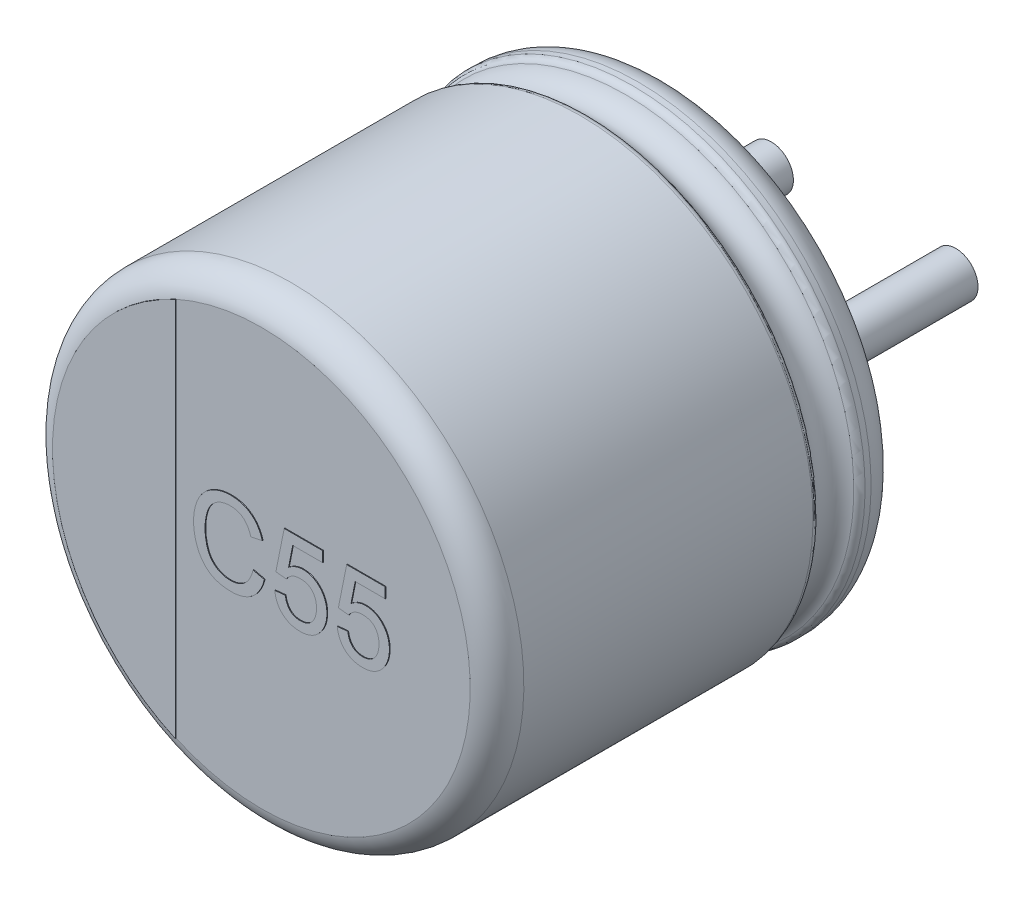
from build123d import *

# Parameters (mm, degrees)
SKETCH_2_R         = 0.3
EXTRUDE_1_DEPTH    = 2.7
EXTRUDE_2_DEPTH    = 0.01
EXTRUDE_1894_DEPTH = 0.01
EXTRUDE_5_DEPTH    = 0.05


with BuildPart() as part:
    # Sketch10 → Повернуть1 (revolve)
    with BuildSketch(Plane(origin=(0, 0, 0), x_dir=(0, 0, -1), z_dir=(1, 0, 0))):
        with BuildLine():
            Line((-5.5, 0), (-0.05, 0))
            Line((-0.05, 0), (-0.05, 2.553143426))
            ThreePointArc((-0.05, 2.553143426), (-0.052704561, 2.951565585), (-0.398206102, 3.15))
            Line((-0.398206102, 3.15), (-0.479422929, 3.15))
            ThreePointArc((-0.479422929, 3.15), (-0.534479696, 3.133479053), (-0.571344666, 3.089375046))
            ThreePointArc((-0.571344666, 3.089375046), (-0.831990181, 2.917472047), (-1.092635697, 3.089375046))
            ThreePointArc((-1.092635697, 3.089375046), (-1.129500666, 3.133479053), (-1.184557434, 3.15))
            Line((-1.184557434, 3.15), (-5.1, 3.15))
            ThreePointArc((-5.1, 3.15), (-5.35971595, 3.059961924), (-5.5, 2.82357323))
            Line((-5.5, 2.82357323), (-5.5, 0))
        make_face()
    revolve(axis=Axis((0, 0, -18.1630778), (0, 0, 1)))

    # Эскиз2 → Бобышка-Вытянуть1 (add)
    with BuildSketch(Plane(origin=(0, 0, 0.05), x_dir=(-1, 0, 0), z_dir=(0, 0, -1))):
        with Locations((-1.25, 0)):
            Circle(SKETCH_2_R)
        with Locations((1.25, 0)):
            Circle(SKETCH_2_R)
    extrude(amount=EXTRUDE_1_DEPTH)

    # Эскиз4 → Бобышка-Вытянуть2 (add)
    with BuildSketch(Plane.XY.offset(5.5)):
        with BuildLine():
            Line((-1.160332513, -2.574139515), (-1.160332513, 2.574139515))
            ThreePointArc((-1.160332513, 2.574139515), (-2.82357323, 0), (-1.160332513, -2.574139515))
        make_face()
    extrude(amount=EXTRUDE_2_DEPTH)

    # Эскиз5 → Extrude 1894 (add)
    with BuildSketch(Plane.XY.offset(5.5)):
        with BuildLine():
            Line((-0.108912855, -0.069918347), (0.04621535, -0.106056167))
            add(Edge.make_bspline(
                [(0.04621535, -0.106056167), (0.042328955, -0.120595903), (0.034726685, -0.149037431), (0.019696074, -0.189740405), (0.002826055, -0.22793841), (-0.016292712, -0.263530826), (-0.037869483, -0.296313018), (-0.061332559, -0.326706301), (-0.08761128, -0.354073299), (-0.115741448, -0.379045627), (-0.145942088, -0.401071154), (-0.177849082, -0.420090601), (-0.2113082, -0.436272289), (-0.246454673, -0.449579116), (-0.283311287, -0.459593644), (-0.321688266, -0.466892819), (-0.361697515, -0.471388685), (-0.388969191, -0.471980579), (-0.402863176, -0.472282129)],
                knots=[0, 0, 0, 0, 4.5129e-05, 8.8278e-05, 0.000130005, 0.00017033, 0.000209322, 0.000247627, 0.000285345, 0.000322969, 0.000360344, 0.000397303, 0.00043426, 0.000471708, 0.000509877, 0.000548685, 0.000588812, 0.000630487, 0.000630487, 0.000630487, 0.000630487], degree=3))
            add(Edge.make_bspline(
                [(-0.402863176, -0.472282129), (-0.417118674, -0.472075022), (-0.445008416, -0.471669834), (-0.48586528, -0.468374144), (-0.524724169, -0.462658281), (-0.561512517, -0.454716909), (-0.596354147, -0.444897895), (-0.629104581, -0.432544706), (-0.659706455, -0.417746474), (-0.68841503, -0.40091706), (-0.715108371, -0.381798088), (-0.740393493, -0.360905526), (-0.763656558, -0.337664227), (-0.785479231, -0.312622937), (-0.805386205, -0.285451329), (-0.824109863, -0.25651854), (-0.840736314, -0.225314775), (-0.855881721, -0.192418552), (-0.869175168, -0.158148367), (-0.880935219, -0.12318115), (-0.890549703, -0.087447226), (-0.898827154, -0.051247288), (-0.904840321, -0.01427674), (-0.90961459, 0.023187027), (-0.912239578, 0.061373697), (-0.912584999, 0.087042498), (-0.912759009, 0.09997348)],
                knots=[0, 0, 0, 0, 4.2763e-05, 8.3662e-05, 0.000122865, 0.000160509, 0.000196497, 0.000231366, 0.000265367, 0.000298359, 0.00033107, 0.000363769, 0.000396646, 0.000429606, 0.00046332, 0.000497611, 0.000532907, 0.000569289, 0.000606199, 0.00064313, 0.000679908, 0.000717169, 0.000754481, 0.000792226, 0.000830438, 0.00086923, 0.00086923, 0.00086923, 0.00086923], degree=3))
            add(Edge.make_bspline(
                [(-0.912759009, 0.09997348), (-0.912510138, 0.113932996), (-0.912018432, 0.141513475), (-0.909242757, 0.182209272), (-0.904144849, 0.221485694), (-0.897065337, 0.259368577), (-0.888106922, 0.295888601), (-0.877048763, 0.331063557), (-0.864030746, 0.364848441), (-0.849092557, 0.397280506), (-0.83213495, 0.427997725), (-0.81366404, 0.457043765), (-0.793239225, 0.483941703), (-0.771466071, 0.509205432), (-0.747800778, 0.532414283), (-0.72231561, 0.553620827), (-0.695230442, 0.573018497), (-0.666549228, 0.590427213), (-0.636646863, 0.605702449), (-0.605967495, 0.619308236), (-0.574389099, 0.630460027), (-0.542162036, 0.639732294), (-0.509216926, 0.647113879), (-0.475476789, 0.652049968), (-0.4409728, 0.655266706), (-0.417707516, 0.655702651), (-0.405948112, 0.655922999)],
                knots=[0, 0, 0, 0, 4.1881e-05, 8.2747e-05, 0.000122296, 0.00016063, 0.000198308, 0.000235036, 0.00027117, 0.000306859, 0.000342067, 0.000376357, 0.000410027, 0.000443298, 0.000476332, 0.000509341, 0.000542667, 0.000576187, 0.000609892, 0.00064334, 0.000676795, 0.000710271, 0.000743899, 0.000777992, 0.000812505, 0.000847779, 0.000847779, 0.000847779, 0.000847779], degree=3))
            add(Edge.make_bspline(
                [(-0.405948112, 0.655922999), (-0.392790923, 0.655674993), (-0.366929166, 0.655187511), (-0.328981645, 0.651177881), (-0.292637827, 0.64446219), (-0.25774023, 0.635651838), (-0.224651675, 0.623588633), (-0.19301293, 0.609246868), (-0.163138738, 0.592016975), (-0.134796652, 0.572372462), (-0.108448038, 0.5502771), (-0.083724175, 0.526258741), (-0.061633171, 0.499717103), (-0.04130009, 0.471294538), (-0.023364678, 0.440596924), (-0.007167108, 0.407891911), (0.006762331, 0.372936375), (0.014215274, 0.348588877), (0.018010222, 0.336191429)],
                knots=[0, 0, 0, 0, 3.9465e-05, 7.7573e-05, 0.00011431, 0.000150279, 0.000185409, 0.000219821, 0.000254368, 0.000288721, 0.000323141, 0.000357421, 0.000391983, 0.00042659, 0.000462151, 0.000498515, 0.000535996, 0.000574881, 0.000574881, 0.000574881, 0.000574881], degree=3))
            Line((0.018010222, 0.336191429), (-0.137117984, 0.302918192))
            add(Edge.make_bspline(
                [(-0.137117984, 0.302918192), (-0.140164459, 0.312432596), (-0.146127355, 0.331055231), (-0.15671506, 0.357595794), (-0.168149428, 0.382234108), (-0.180702836, 0.404802692), (-0.194402488, 0.425306953), (-0.20893292, 0.443996089), (-0.224642265, 0.460521265), (-0.241210981, 0.47526351), (-0.259066923, 0.487822492), (-0.277791469, 0.498951816), (-0.297779426, 0.508159635), (-0.318743252, 0.515947548), (-0.340878894, 0.521874989), (-0.364096214, 0.526045177), (-0.388415609, 0.528458678), (-0.404987911, 0.528817113), (-0.413440099, 0.528999922)],
                knots=[0, 0, 0, 0, 2.9963e-05, 5.8647e-05, 8.5657e-05, 0.000111404, 0.000136034, 0.000159573, 0.00018233, 0.000204345, 0.00022599, 0.00024772, 0.000269605, 0.000291914, 0.000314738, 0.000338251, 0.000362611, 0.000387967, 0.000387967, 0.000387967, 0.000387967], degree=3))
            add(Edge.make_bspline(
                [(-0.413440099, 0.528999922), (-0.423143984, 0.528859129), (-0.442228662, 0.528582229), (-0.47026635, 0.525551592), (-0.497192283, 0.52108776), (-0.522805782, 0.51439386), (-0.547247006, 0.506048307), (-0.570370917, 0.495656617), (-0.592374217, 0.483476338), (-0.613011338, 0.469434324), (-0.632108844, 0.453648399), (-0.650184985, 0.436960206), (-0.666371907, 0.418591447), (-0.681286864, 0.399147811), (-0.694495535, 0.378285716), (-0.706385552, 0.356289328), (-0.716881124, 0.332978371), (-0.72832201, 0.300169965), (-0.739987527, 0.257913496), (-0.750107378, 0.206205274), (-0.756553484, 0.153682392), (-0.757270938, 0.118354545), (-0.757630804, 0.100634538)],
                knots=[0, 0, 0, 0, 2.91e-05, 5.7231e-05, 8.4509e-05, 0.000110911, 0.000136555, 0.000161905, 0.00018686, 0.000211918, 0.000236663, 0.000261138, 0.00028564, 0.000310012, 0.000334585, 0.000359628, 0.000384977, 0.000411183, 0.00046379, 0.000516339, 0.000569145, 0.000622287, 0.000622287, 0.000622287, 0.000622287], degree=3))
            add(Edge.make_bspline(
                [(-0.757630804, 0.100634538), (-0.757224926, 0.078354594), (-0.756437487, 0.035129485), (-0.748667393, -0.027510838), (-0.73682082, -0.085937398), (-0.722523713, -0.131521756), (-0.708182278, -0.165145637), (-0.696583647, -0.188692925), (-0.683344271, -0.210482444), (-0.668793463, -0.230637938), (-0.652743794, -0.249100614), (-0.635418867, -0.265968548), (-0.616814812, -0.281404048), (-0.59671119, -0.29468455), (-0.575881813, -0.306476479), (-0.554589531, -0.316962087), (-0.53282094, -0.32583035), (-0.51048821, -0.332719396), (-0.487904955, -0.338672491), (-0.464822442, -0.342561331), (-0.441247254, -0.34475607), (-0.425417098, -0.345156447), (-0.417406445, -0.345359052)],
                knots=[0, 0, 0, 0, 6.6811e-05, 0.000129619, 0.000189041, 0.000245488, 0.000272541, 0.000298655, 0.000324164, 0.000348934, 0.000373146, 0.000397455, 0.000421409, 0.000445549, 0.000469628, 0.000493181, 0.000516709, 0.000540055, 0.00056325, 0.000586724, 0.000610185, 0.00063422, 0.00063422, 0.00063422, 0.00063422], degree=3))
            add(Edge.make_bspline(
                [(-0.417406445, -0.345359052), (-0.407846827, -0.345158567), (-0.388963202, -0.344762537), (-0.361277409, -0.34129607), (-0.334588687, -0.336187777), (-0.309220365, -0.328305166), (-0.284831211, -0.318653832), (-0.261621051, -0.306752049), (-0.239662879, -0.292437677), (-0.218698419, -0.276185053), (-0.199114272, -0.257692345), (-0.181166455, -0.237108537), (-0.165065235, -0.214339793), (-0.150135352, -0.189751516), (-0.137591507, -0.162609165), (-0.125972944, -0.133721734), (-0.116291518, -0.102614431), (-0.111407741, -0.080973603), (-0.108912855, -0.069918347)],
                knots=[0, 0, 0, 0, 2.8667e-05, 5.6627e-05, 8.3593e-05, 0.000110082, 0.000136188, 0.000162205, 0.000188181, 0.000214716, 0.000241683, 0.000268859, 0.000296498, 0.000325256, 0.000355023, 0.00038608, 0.000418627, 0.000452619, 0.000452619, 0.000452619, 0.000452619], degree=3))
        make_face()
        with BuildLine():
            Line((0.187240991, -0.162025719), (0.328266632, -0.147923155))
            add(Edge.make_bspline(
                [(0.328266632, -0.147923155), (0.329663007, -0.155869175), (0.332379174, -0.171325422), (0.337555131, -0.193698797), (0.344277225, -0.214484288), (0.351830237, -0.233861909), (0.360808267, -0.251626765), (0.370536037, -0.268059356), (0.382007953, -0.282576374), (0.394069133, -0.295937074), (0.4073072, -0.307710214), (0.42184989, -0.317635377), (0.437291454, -0.32629448), (0.453819964, -0.333384169), (0.471460751, -0.338573449), (0.489989297, -0.342677278), (0.509644188, -0.344745178), (0.523054586, -0.345151811), (0.529889228, -0.345359052)],
                knots=[0, 0, 0, 0, 2.4203e-05, 4.7078e-05, 6.882e-05, 8.9689e-05, 0.000109398, 0.000128482, 0.000146862, 0.000164797, 0.000182438, 0.000199858, 0.000217515, 0.000235483, 0.000253676, 0.000272606, 0.000292341, 0.000312853, 0.000312853, 0.000312853, 0.000312853], degree=3))
            add(Edge.make_bspline(
                [(0.529889228, -0.345359052), (0.538273802, -0.345156456), (0.554670202, -0.344760272), (0.578523859, -0.341409501), (0.601055569, -0.335884469), (0.622157523, -0.328152597), (0.642077099, -0.318537099), (0.660153478, -0.306086781), (0.677372284, -0.292091393), (0.692625482, -0.275406205), (0.706510178, -0.25724159), (0.718493714, -0.237414141), (0.728582159, -0.21620215), (0.737075526, -0.193609686), (0.743347259, -0.169507684), (0.747960624, -0.144024363), (0.750922221, -0.11714349), (0.751201119, -0.098718979), (0.751343555, -0.089309372)],
                knots=[0, 0, 0, 0, 2.5144e-05, 4.9171e-05, 7.2098e-05, 9.4614e-05, 0.000116491, 0.000138248, 0.000160311, 0.000182917, 0.000205878, 0.000228817, 0.000252274, 0.000276259, 0.000301113, 0.000326873, 0.000353908, 0.000382127, 0.000382127, 0.000382127, 0.000382127], degree=3))
            add(Edge.make_bspline(
                [(0.751343555, -0.089309372), (0.751181664, -0.08034214), (0.750866425, -0.062880858), (0.7482116, -0.037454328), (0.743732597, -0.013545695), (0.737937186, 0.009108555), (0.729948943, 0.030154423), (0.720474438, 0.049897053), (0.708867771, 0.067917448), (0.695954587, 0.084776698), (0.681206101, 0.099890336), (0.664423064, 0.112651889), (0.646263863, 0.123820825), (0.626362754, 0.132878135), (0.604708018, 0.139607376), (0.581514844, 0.144784922), (0.556542567, 0.147508099), (0.53937003, 0.1479855), (0.530550286, 0.148230692)],
                knots=[0, 0, 0, 0, 2.6897e-05, 5.2376e-05, 7.6578e-05, 9.9828e-05, 0.000122421, 0.000144003, 0.000165399, 0.000186599, 0.000207635, 0.000228526, 0.00024969, 0.000271482, 0.000293921, 0.000317607, 0.000342671, 0.000369136, 0.000369136, 0.000369136, 0.000369136], degree=3))
            add(Edge.make_bspline(
                [(0.530550286, 0.148230692), (0.519583361, 0.147909888), (0.498551282, 0.147294658), (0.468330346, 0.142118954), (0.440819135, 0.133758262), (0.416329128, 0.121297669), (0.394448517, 0.106411443), (0.374722744, 0.089567003), (0.35698915, 0.070775738), (0.347261552, 0.056628096), (0.342369196, 0.049512743)],
                knots=[0, 0, 0, 0, 3.288e-05, 6.3056e-05, 9.1699e-05, 0.000118799, 0.00014514, 0.000170929, 0.000196499, 0.000222372, 0.000222372, 0.000222372, 0.000222372], degree=3))
            Line((0.342369196, 0.049512743), (0.201343555, 0.063615307))
            Line((0.201343555, 0.063615307), (0.314164068, 0.627717871))
            Line((0.314164068, 0.627717871), (0.835958939, 0.627717871))
            Line((0.835958939, 0.627717871), (0.835958939, 0.48669223))
            Line((0.835958939, 0.48669223), (0.429408459, 0.48669223))
            Line((0.429408459, 0.48669223), (0.373438907, 0.201776365))
            add(Edge.make_bspline(
                [(0.373438907, 0.201776365), (0.381220325, 0.207615649), (0.396501797, 0.21908308), (0.420338155, 0.23409817), (0.444515348, 0.246754889), (0.468892634, 0.257119678), (0.493663653, 0.26519383), (0.518678924, 0.270803378), (0.544023622, 0.274594641), (0.561018736, 0.274966861), (0.569552689, 0.275153769)],
                knots=[0, 0, 0, 0, 2.9177e-05, 5.73e-05, 8.4404e-05, 0.000110965, 0.000136679, 0.000162444, 0.00018781, 0.000213395, 0.000213395, 0.000213395, 0.000213395], degree=3))
            add(Edge.make_bspline(
                [(0.569552689, 0.275153769), (0.580659052, 0.274862773), (0.602530172, 0.274289732), (0.634758026, 0.269581481), (0.665573276, 0.261588913), (0.695217633, 0.250824089), (0.723300203, 0.236553476), (0.750105442, 0.219274793), (0.775525128, 0.198845618), (0.799415555, 0.175651407), (0.821085123, 0.149903394), (0.840480093, 0.122441316), (0.856320846, 0.092715457), (0.869644006, 0.061501965), (0.879692618, 0.028288459), (0.887319866, -0.006453695), (0.891397902, -0.043158851), (0.892040364, -0.068146518), (0.892369196, -0.080935975)],
                knots=[0, 0, 0, 0, 3.3309e-05, 6.5593e-05, 9.7446e-05, 0.000128679, 0.000160016, 0.000191739, 0.00022419, 0.000257693, 0.000291466, 0.000325024, 0.00035835, 0.000392319, 0.00042668, 0.000462293, 0.000498891, 0.000537264, 0.000537264, 0.000537264, 0.000537264], degree=3))
            add(Edge.make_bspline(
                [(0.892369196, -0.080935975), (0.892119496, -0.09313922), (0.891626269, -0.117244111), (0.887584166, -0.152767124), (0.880925762, -0.186996344), (0.872011997, -0.220033132), (0.859968304, -0.251689867), (0.845360431, -0.282068801), (0.828509431, -0.311486928), (0.814995803, -0.329621506), (0.808194516, -0.338748475)],
                knots=[0, 0, 0, 0, 3.6602e-05, 7.23e-05, 0.000107089, 0.000141142, 0.000174824, 0.000208531, 0.000242205, 0.000276325, 0.000276325, 0.000276325, 0.000276325], degree=3))
            add(Edge.make_bspline(
                [(0.808194516, -0.338748475), (0.799553673, -0.34940252), (0.782556205, -0.37036017), (0.753125276, -0.397561946), (0.72148661, -0.420679711), (0.687451922, -0.43946122), (0.651249697, -0.454553753), (0.612435201, -0.464597267), (0.57147744, -0.471341885), (0.543359143, -0.471964402), (0.529007818, -0.472282129)],
                knots=[0, 0, 0, 0, 4.1109e-05, 8.0866e-05, 0.000119829, 0.000158396, 0.000197229, 0.000237158, 0.000278421, 0.000321435, 0.000321435, 0.000321435, 0.000321435], degree=3))
            add(Edge.make_bspline(
                [(0.529007818, -0.472282129), (0.517170251, -0.472042006), (0.494013596, -0.471572277), (0.460108131, -0.467488675), (0.427860025, -0.460976771), (0.397259175, -0.451636685), (0.368213388, -0.439834611), (0.341060284, -0.424841931), (0.31532865, -0.407691239), (0.291584496, -0.387854125), (0.269950481, -0.365728117), (0.250565963, -0.341782016), (0.23369327, -0.316000209), (0.219340543, -0.288536968), (0.207378208, -0.259418631), (0.198226549, -0.228446455), (0.190977673, -0.195924323), (0.188499612, -0.173443732), (0.187240991, -0.162025719)],
                knots=[0, 0, 0, 0, 3.5501e-05, 6.9448e-05, 0.000102291, 0.000134077, 0.0001653, 0.000196163, 0.000226965, 0.000257944, 0.000288796, 0.000319665, 0.000350223, 0.000381074, 0.0004125, 0.000444497, 0.000477862, 0.0005123, 0.0005123, 0.0005123, 0.0005123], degree=3))
        make_face()
        with BuildLine():
            Line((1.033394837, -0.162025719), (1.174420478, -0.147923155))
            add(Edge.make_bspline(
                [(1.174420478, -0.147923155), (1.175816853, -0.155869175), (1.17853302, -0.171325422), (1.183708977, -0.193698797), (1.190431071, -0.214484288), (1.197984084, -0.233861909), (1.206962113, -0.251626765), (1.216689883, -0.268059356), (1.2281618, -0.282576374), (1.240222979, -0.295937074), (1.253461046, -0.307710214), (1.268003736, -0.317635377), (1.2834453, -0.32629448), (1.29997381, -0.333384169), (1.317614597, -0.338573449), (1.336143143, -0.342677278), (1.355798034, -0.344745178), (1.369208432, -0.345151811), (1.376043074, -0.345359052)],
                knots=[0, 0, 0, 0, 2.4203e-05, 4.7078e-05, 6.882e-05, 8.9689e-05, 0.000109398, 0.000128482, 0.000146862, 0.000164797, 0.000182438, 0.000199858, 0.000217515, 0.000235483, 0.000253676, 0.000272606, 0.000292341, 0.000312853, 0.000312853, 0.000312853, 0.000312853], degree=3))
            add(Edge.make_bspline(
                [(1.376043074, -0.345359052), (1.384427648, -0.345156456), (1.400824049, -0.344760272), (1.424677705, -0.341409501), (1.447209416, -0.335884469), (1.468311369, -0.328152597), (1.488230945, -0.318537099), (1.506307324, -0.306086781), (1.52352613, -0.292091393), (1.538779328, -0.275406205), (1.552664024, -0.25724159), (1.56464756, -0.237414141), (1.574736005, -0.21620215), (1.583229373, -0.193609686), (1.589501105, -0.169507684), (1.59411447, -0.144024363), (1.597076067, -0.11714349), (1.597354965, -0.098718979), (1.597497401, -0.089309372)],
                knots=[0, 0, 0, 0, 2.5144e-05, 4.9171e-05, 7.2098e-05, 9.4614e-05, 0.000116491, 0.000138248, 0.000160311, 0.000182917, 0.000205878, 0.000228817, 0.000252274, 0.000276259, 0.000301113, 0.000326873, 0.000353908, 0.000382127, 0.000382127, 0.000382127, 0.000382127], degree=3))
            add(Edge.make_bspline(
                [(1.597497401, -0.089309372), (1.59733551, -0.08034214), (1.597020271, -0.062880858), (1.594365446, -0.037454328), (1.589886443, -0.013545695), (1.584091032, 0.009108555), (1.57610279, 0.030154423), (1.566628284, 0.049897053), (1.555021617, 0.067917448), (1.542108433, 0.084776698), (1.527359948, 0.099890336), (1.51057691, 0.112651889), (1.492417709, 0.123820825), (1.4725166, 0.132878135), (1.450861864, 0.139607376), (1.42766869, 0.144784922), (1.402696413, 0.147508099), (1.385523876, 0.1479855), (1.376704132, 0.148230692)],
                knots=[0, 0, 0, 0, 2.6897e-05, 5.2376e-05, 7.6578e-05, 9.9828e-05, 0.000122421, 0.000144003, 0.000165399, 0.000186599, 0.000207635, 0.000228526, 0.00024969, 0.000271482, 0.000293921, 0.000317607, 0.000342671, 0.000369136, 0.000369136, 0.000369136, 0.000369136], degree=3))
            add(Edge.make_bspline(
                [(1.376704132, 0.148230692), (1.365737207, 0.147909888), (1.344705128, 0.147294658), (1.314484193, 0.142118954), (1.286972981, 0.133758262), (1.262482974, 0.121297669), (1.240602363, 0.106411443), (1.22087659, 0.089567003), (1.203142996, 0.070775738), (1.193415398, 0.056628096), (1.188523042, 0.049512743)],
                knots=[0, 0, 0, 0, 3.288e-05, 6.3056e-05, 9.1699e-05, 0.000118799, 0.00014514, 0.000170929, 0.000196499, 0.000222372, 0.000222372, 0.000222372, 0.000222372], degree=3))
            Line((1.188523042, 0.049512743), (1.047497401, 0.063615307))
            Line((1.047497401, 0.063615307), (1.160317914, 0.627717871))
            Line((1.160317914, 0.627717871), (1.682112786, 0.627717871))
            Line((1.682112786, 0.627717871), (1.682112786, 0.48669223))
            Line((1.682112786, 0.48669223), (1.275562305, 0.48669223))
            Line((1.275562305, 0.48669223), (1.219592754, 0.201776365))
            add(Edge.make_bspline(
                [(1.219592754, 0.201776365), (1.227374171, 0.207615649), (1.242655643, 0.21908308), (1.266492001, 0.23409817), (1.290669194, 0.246754889), (1.31504648, 0.257119678), (1.339817499, 0.26519383), (1.364832771, 0.270803378), (1.390177468, 0.274594641), (1.407172582, 0.274966861), (1.415706536, 0.275153769)],
                knots=[0, 0, 0, 0, 2.9177e-05, 5.73e-05, 8.4404e-05, 0.000110965, 0.000136679, 0.000162444, 0.00018781, 0.000213395, 0.000213395, 0.000213395, 0.000213395], degree=3))
            add(Edge.make_bspline(
                [(1.415706536, 0.275153769), (1.426812898, 0.274862773), (1.448684019, 0.274289732), (1.480911872, 0.269581481), (1.511727122, 0.261588913), (1.541371479, 0.250824089), (1.569454049, 0.236553476), (1.596259288, 0.219274793), (1.621678974, 0.198845618), (1.645569401, 0.175651407), (1.667238969, 0.149903394), (1.686633939, 0.122441316), (1.702474692, 0.092715457), (1.715797852, 0.061501965), (1.725846465, 0.028288459), (1.733473712, -0.006453695), (1.737551748, -0.043158851), (1.73819421, -0.068146518), (1.738523042, -0.080935975)],
                knots=[0, 0, 0, 0, 3.3309e-05, 6.5593e-05, 9.7446e-05, 0.000128679, 0.000160016, 0.000191739, 0.00022419, 0.000257693, 0.000291466, 0.000325024, 0.00035835, 0.000392319, 0.00042668, 0.000462293, 0.000498891, 0.000537264, 0.000537264, 0.000537264, 0.000537264], degree=3))
            add(Edge.make_bspline(
                [(1.738523042, -0.080935975), (1.738273343, -0.09313922), (1.737780115, -0.117244111), (1.733738012, -0.152767124), (1.727079608, -0.186996344), (1.718165843, -0.220033132), (1.70612215, -0.251689867), (1.691514277, -0.282068801), (1.674663277, -0.311486928), (1.661149649, -0.329621506), (1.654348363, -0.338748475)],
                knots=[0, 0, 0, 0, 3.6602e-05, 7.23e-05, 0.000107089, 0.000141142, 0.000174824, 0.000208531, 0.000242205, 0.000276325, 0.000276325, 0.000276325, 0.000276325], degree=3))
            add(Edge.make_bspline(
                [(1.654348363, -0.338748475), (1.645707519, -0.34940252), (1.628710052, -0.37036017), (1.599279123, -0.397561946), (1.567640457, -0.420679711), (1.533605768, -0.43946122), (1.497403543, -0.454553753), (1.458589047, -0.464597267), (1.417631286, -0.471341885), (1.389512989, -0.471964402), (1.375161664, -0.472282129)],
                knots=[0, 0, 0, 0, 4.1109e-05, 8.0866e-05, 0.000119829, 0.000158396, 0.000197229, 0.000237158, 0.000278421, 0.000321435, 0.000321435, 0.000321435, 0.000321435], degree=3))
            add(Edge.make_bspline(
                [(1.375161664, -0.472282129), (1.363324098, -0.472042006), (1.340167442, -0.471572277), (1.306261977, -0.467488675), (1.274013871, -0.460976771), (1.243413021, -0.451636685), (1.214367234, -0.439834611), (1.18721413, -0.424841931), (1.161482496, -0.407691239), (1.137738342, -0.387854125), (1.116104327, -0.365728117), (1.096719809, -0.341782016), (1.079847116, -0.316000209), (1.065494389, -0.288536968), (1.053532054, -0.259418631), (1.044380395, -0.228446455), (1.03713152, -0.195924323), (1.034653458, -0.173443732), (1.033394837, -0.162025719)],
                knots=[0, 0, 0, 0, 3.5501e-05, 6.9448e-05, 0.000102291, 0.000134077, 0.0001653, 0.000196163, 0.000226965, 0.000257944, 0.000288796, 0.000319665, 0.000350223, 0.000381074, 0.0004125, 0.000444497, 0.000477862, 0.0005123, 0.0005123, 0.0005123, 0.0005123], degree=3))
        make_face()
    extrude(amount=EXTRUDE_1894_DEPTH)

    # Эскиз6 → Бобышка-Вытянуть5 (add)
    with BuildSketch(Plane(origin=(0, 0, 0.05), x_dir=(-1, 0, 0), z_dir=(0, 0, -1))):
        with BuildLine():
            Line((-1.25, 0.4), (-1.624807681, 0.4))
            ThreePointArc((-1.624807681, 0.4), (-1.831827349, 0.509847022), (-1.856923064, 0.742857143))
            ThreePointArc((-1.856923064, 0.742857143), (0, 2), (1.856923064, 0.742857143))
            ThreePointArc((1.856923064, 0.742857143), (1.831827349, 0.509847022), (1.624807681, 0.4))
            Line((1.624807681, 0.4), (1.25, 0.4))
            ThreePointArc((1.25, 0.4), (0.85, 0), (1.25, -0.4))
            Line((1.25, -0.4), (1.624807681, -0.4))
            ThreePointArc((1.624807681, -0.4), (1.831827349, -0.509847022), (1.856923064, -0.742857143))
            ThreePointArc((1.856923064, -0.742857143), (0, -2), (-1.856923064, -0.742857143))
            ThreePointArc((-1.856923064, -0.742857143), (-1.831827349, -0.509847022), (-1.624807681, -0.4))
            Line((-1.624807681, -0.4), (-1.25, -0.4))
            ThreePointArc((-1.25, -0.4), (-0.85, 0), (-1.25, 0.4))
        make_face()
    extrude(amount=EXTRUDE_5_DEPTH)


solid = part.part
